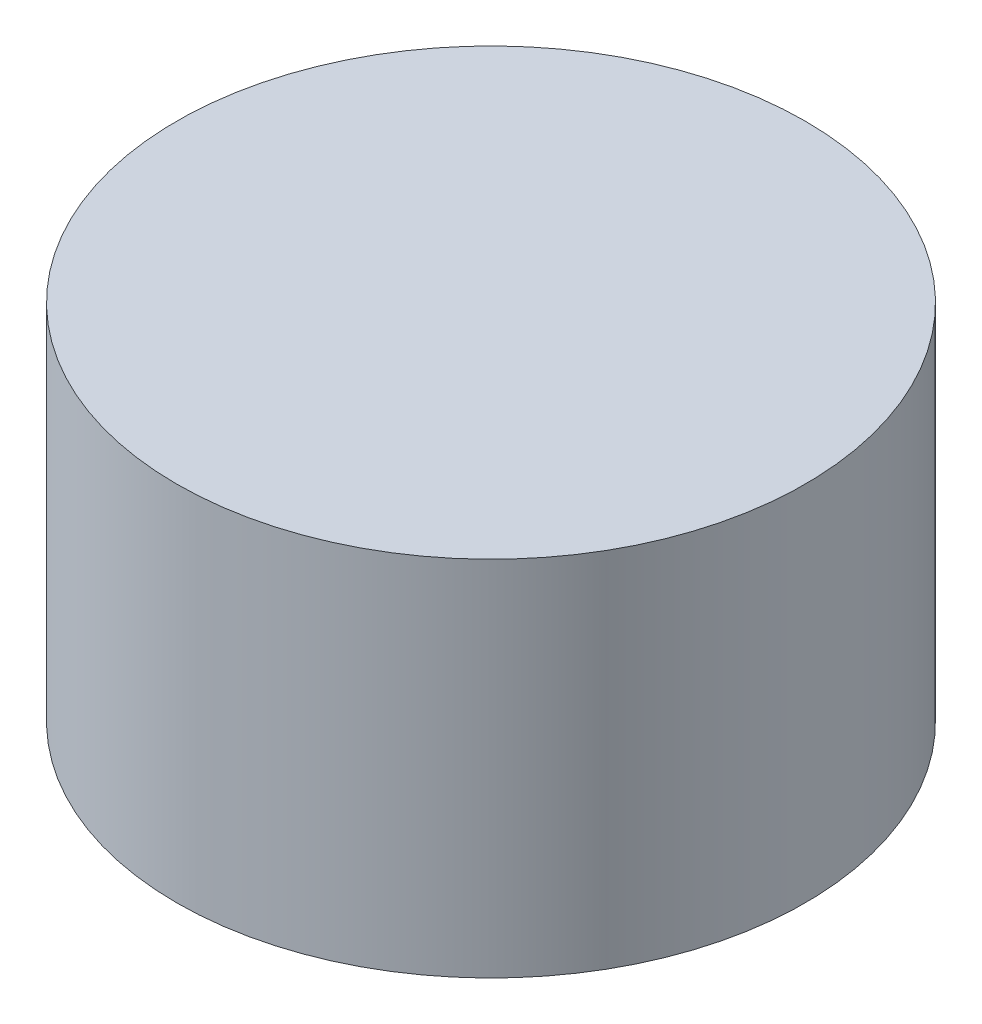
from build123d import *

# Parameters (mm, degrees)
SKETCH1_R           = 33.02
BOSS_EXTRUDE1_DEPTH = 38.1


with BuildPart() as part:
    # Sketch1 → Boss-Extrude1 (new body)
    with BuildSketch(Plane(origin=(0, 0, 0), x_dir=(1, 0, 0), z_dir=(0, 1, 0))):
        Circle(SKETCH1_R)
    extrude(amount=BOSS_EXTRUDE1_DEPTH)


solid = part.part
